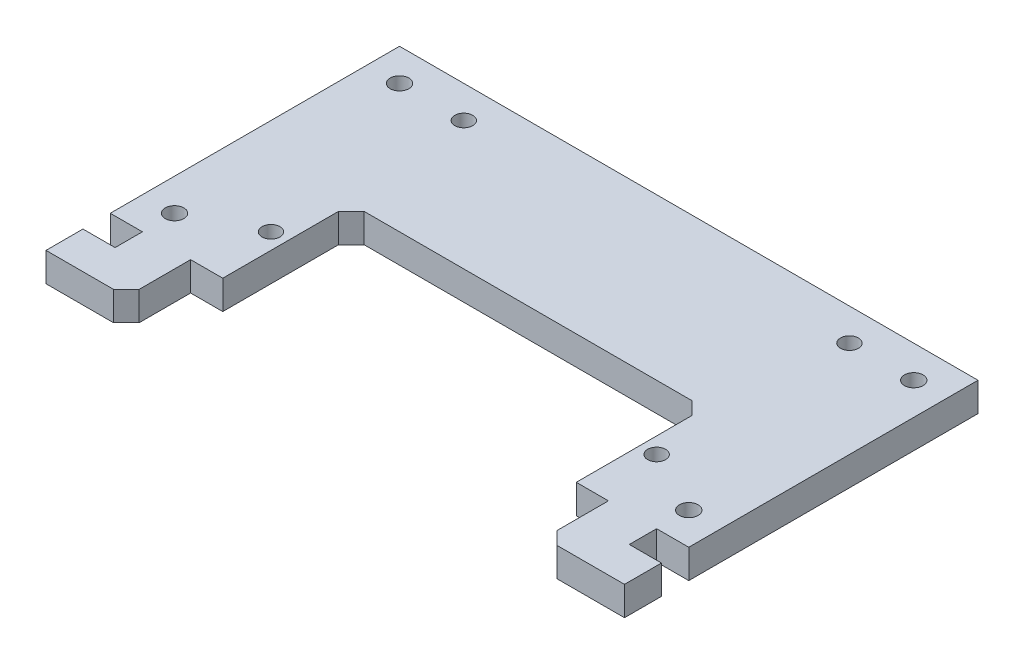
from build123d import *

# Parameters (mm, degrees)
SKETCH1_W           = 90
SKETCH1_H           = 55
SKETCH1_R           = 1.45
BOSS_EXTRUDE1_DEPTH = 4.5
SKETCH2_W           = 5
SKETCH2_H           = 4.25
CUT_EXTRUDE1_DEPTH  = 5.5
SKETCH3_R           = 1.4
CUT_EXTRUDE2_DEPTH  = 5.5
SKETCH4_W           = 55
SKETCH4_H           = 30
CUT_EXTRUDE3_DEPTH  = 5.5
SKETCH5_W           = 65
SKETCH5_H           = 10
CUT_EXTRUDE4_DEPTH  = 5.5
CHAMFER1_SIZE       = 2


with BuildPart() as part:
    # Sketch1 → Boss-Extrude1 (new body)
    with BuildSketch(Plane(origin=(0, 0, 0), x_dir=(1, 0, 0), z_dir=(0, 1, 0))):
        with Locations((0, -27.5)):
            Rectangle(SKETCH1_W, SKETCH1_H)
        with Locations((-40, -40)):
            Circle(SKETCH1_R, mode=Mode.SUBTRACT)
        with Locations((-40, -5)):
            Circle(SKETCH1_R, mode=Mode.SUBTRACT)
        with Locations((40, -40)):
            Circle(SKETCH1_R, mode=Mode.SUBTRACT)
        with Locations((40, -5)):
            Circle(SKETCH1_R, mode=Mode.SUBTRACT)
    extrude(amount=BOSS_EXTRUDE1_DEPTH)

    # Sketch2 → Cut-Extrude1 (cut, through all)
    with BuildSketch(Plane(origin=(0, 4.5, 0), x_dir=(1, 0, 0), z_dir=(0, 1, 0))):
        with Locations((-42.5, -47.125)):
            Rectangle(SKETCH2_W, SKETCH2_H)
        with Locations((42.5, -47.125)):
            Rectangle(SKETCH2_W, SKETCH2_H)
    extrude(amount=-CUT_EXTRUDE1_DEPTH, mode=Mode.SUBTRACT)

    # Sketch3 → Cut-Extrude2 (cut, through all)
    with BuildSketch(Plane(origin=(0, 4.5, 0), x_dir=(1, 0, 0), z_dir=(0, 1, 0))):
        with Locations((-30, -35)):
            Circle(SKETCH3_R)
        with Locations((-30, -5)):
            Circle(SKETCH3_R)
    cut_extrude2 = extrude(amount=-CUT_EXTRUDE2_DEPTH, mode=Mode.SUBTRACT)

    # Mirror1: Cut-Extrude2 across plane
    add(cut_extrude2.mirror(Plane(origin=(0, 0, 0), x_dir=(0, 0, 1), z_dir=(1, 0, 0))), mode=Mode.SUBTRACT)

    # Sketch4 → Cut-Extrude3 (cut, through all)
    with BuildSketch(Plane(origin=(0, 4.5, 0), x_dir=(1, 0, 0), z_dir=(0, 1, 0))):
        with Locations((0, -40)):
            Rectangle(SKETCH4_W, SKETCH4_H)
    extrude(amount=-CUT_EXTRUDE3_DEPTH, mode=Mode.SUBTRACT)

    # Sketch5 → Cut-Extrude4 (cut, through all)
    with BuildSketch(Plane(origin=(0, 4.5, 0), x_dir=(1, 0, 0), z_dir=(0, 1, 0))):
        with Locations((0, -50)):
            Rectangle(SKETCH5_W, SKETCH5_H)
    extrude(amount=-CUT_EXTRUDE4_DEPTH, mode=Mode.SUBTRACT)

    # Chamfer1
    chamfer1_edges = [part.edges().sort_by_distance(p)[0] for p in [
        (32.5, 2.25, 55),
        (-32.5, 2.25, 55),
        (-27.5, 2.25, 25),
        (27.5, 2.25, 25),
    ]]
    chamfer(chamfer1_edges, length=CHAMFER1_SIZE)


solid = part.part
